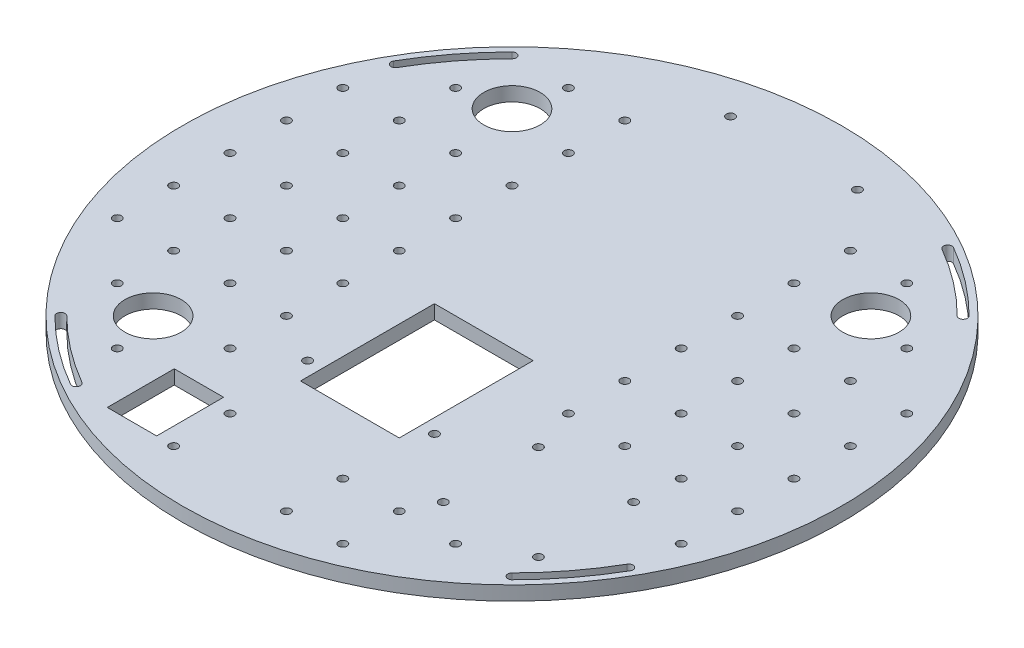
from build123d import *

# Parameters (mm, degrees)
SKETCH18_R            = 148.43125
BOSS_EXTRUDE1_DEPTH   = 6.35
F_6_CLEARANCE_HOLE1_D = 3.7973
CUT_EXTRUDE1_DEPTH    = 6.35
F_6_CLEARANCE_HOLE2_D = 3.7973
SKETCH29_W            = 44.45
SKETCH29_H            = 60.325
CUT_EXTRUDE2_DEPTH    = 7.35
SKETCH30_R            = 12.7
SKETCH30_W            = 22.225
SKETCH30_H            = 30.1625
CUT_EXTRUDE3_DEPTH    = 6.35
F_6_CLEARANCE_HOLE3_D = 3.7973


with BuildPart() as part:
    # Sketch18 → Boss-Extrude1 (new body)
    with BuildSketch(Plane(origin=(0, 0, 0), x_dir=(1, 0, 0), z_dir=(0, 1, 0))):
        Circle(SKETCH18_R)
    extrude(amount=BOSS_EXTRUDE1_DEPTH)

    # #6 Clearance Hole1 (through all)
    with Locations(Plane(origin=(0, 6.35, 0), x_dir=(1, 0, 0), z_dir=(0, 1, 0))):
        with Locations((-101.6, 101.6), (101.6, 101.6), (101.6, -101.6), (-101.6, -101.6), (-124.434078933, 71.842048969), (-71.842048969, -124.434078933), (124.434078933, -71.842048969), (71.842048969, 124.434078933)):
            Hole(F_6_CLEARANCE_HOLE1_D / 2)

    # Sketch23 → Cut-Extrude1 (cut)
    with BuildSketch(Plane(origin=(0, 6.35, 0), x_dir=(1, 0, 0), z_dir=(0, 1, 0))):
        with BuildLine():
            ThreePointArc((-72.791373969, -126.078358066), (-73.486328101, -123.484753933), (-70.892723969, -122.7897998))
            ThreePointArc((-70.892723969, -122.7897998), (-86.313511899, -112.485958726), (-100.25745171, -100.25745171))
            ThreePointArc((-100.25745171, -100.25745171), (-99.845876126, -100.873418101), (-99.70135, -101.6))
            ThreePointArc((-99.70135, -101.6), (-100.873418101, -103.354123874), (-102.94254829, -102.94254829))
            ThreePointArc((-102.94254829, -102.94254829), (-88.625161673, -115.498559365), (-72.791373969, -126.078358066))
        make_face()
        with BuildLine():
            ThreePointArc((-100.25745171, 100.25745171), (-102.94254829, 100.25745171), (-102.94254829, 102.94254829))
            ThreePointArc((-102.94254829, 102.94254829), (-115.498559365, 88.625161673), (-126.078358066, 72.791373969))
            ThreePointArc((-126.078358066, 72.791373969), (-123.942672153, 73.676004039), (-122.535428933, 71.842048969))
            ThreePointArc((-122.535428933, 71.842048969), (-122.600123863, 71.350642189), (-122.7897998, 70.892723969))
            ThreePointArc((-122.7897998, 70.892723969), (-112.485958726, 86.313511899), (-100.25745171, 100.25745171))
        make_face()
        with BuildLine():
            ThreePointArc((100.25745171, 100.25745171), (100.25745171, 102.94254829), (102.94254829, 102.94254829))
            ThreePointArc((102.94254829, 102.94254829), (88.625161673, 115.498559365), (72.791373969, 126.078358066))
            ThreePointArc((72.791373969, 126.078358066), (73.486328101, 125.383403933), (73.740698969, 124.434078933))
            ThreePointArc((73.740698969, 124.434078933), (72.791373969, 122.7897998), (70.892723969, 122.7897998))
            ThreePointArc((70.892723969, 122.7897998), (86.313511899, 112.485958726), (100.25745171, 100.25745171))
        make_face()
        with BuildLine():
            ThreePointArc((126.078358066, -72.791373969), (123.484753933, -73.486328101), (122.7897998, -70.892723969))
            ThreePointArc((122.7897998, -70.892723969), (112.485958726, -86.313511899), (100.25745171, -100.25745171))
            ThreePointArc((100.25745171, -100.25745171), (102.326581899, -99.845876126), (103.49865, -101.6))
            ThreePointArc((103.49865, -101.6), (103.354123874, -102.326581899), (102.94254829, -102.94254829))
            ThreePointArc((102.94254829, -102.94254829), (115.498559365, -88.625161673), (126.078358066, -72.791373969))
        make_face()
    extrude(amount=-CUT_EXTRUDE1_DEPTH, mode=Mode.SUBTRACT)

    # #6 Clearance Hole2 (through all)
    with Locations(Plane(origin=(0, 6.35, 0), x_dir=(1, 0, 0), z_dir=(0, 1, 0))):
        with Locations((57.15, -45.24375), (57.15, -88.10625), (100.0125, -88.10625), (100.0125, -45.24375), (-28.575, -63.5), (28.575, -63.5), (-28.575, 127), (28.575, 127)):
            Hole(F_6_CLEARANCE_HOLE2_D / 2)

    # Sketch29 → Cut-Extrude2 (cut, through all)
    with BuildSketch(Plane(origin=(0, 6.35, 0), x_dir=(1, 0, 0), z_dir=(0, 1, 0))):
        with Locations((0, -42.8625)):
            Rectangle(SKETCH29_W, SKETCH29_H)
    extrude(amount=-CUT_EXTRUDE2_DEPTH, mode=Mode.SUBTRACT)

    # Sketch30 → Cut-Extrude3 (cut)
    with BuildSketch(Plane(origin=(0, 6.35, 0), x_dir=(1, 0, 0), z_dir=(0, 1, 0))):
        with Locations((-80.82230509, 80.82230509)):
            Circle(SKETCH30_R)
        with Locations((80.82230509, 80.82230509)):
            Circle(SKETCH30_R)
        with Locations((-80.82230509, -80.82230509)):
            Circle(SKETCH30_R)
        with Locations((-44.30980509, -111.77855509)):
            Rectangle(SKETCH30_W, SKETCH30_H)
    extrude(amount=-CUT_EXTRUDE3_DEPTH, mode=Mode.SUBTRACT)

    # #6 Clearance Hole3 (through all)
    with Locations(Plane(origin=(0, 6.35, 0), x_dir=(1, 0, 0), z_dir=(0, 1, 0))):
        with Locations((-50.8, 101.6), (-76.2, 101.6), (-101.6, 76.2), (-50.8, 76.2), (-50.8, 50.8), (-76.2, 50.8), (-101.6, 50.8), (-127, 50.8), (-50.8, 25.4), (-76.2, 25.4), (-101.6, 25.4), (-127, 25.4), (-101.6, 0), (-127, 0), (-127, -25.4), (-101.6, -25.4), (-127, -50.8), (-101.6, -50.8), (-101.6, -76.2), (-76.2, -101.6), (-50.8, -76.2), (-76.2, -50.8), (-50.8, -50.8), (-50.8, -25.4), (-76.2, -25.4), (-76.2, 0), (-50.8, 0), (50.8, 101.6), (76.2, 101.6), (50.8, 76.2), (101.6, 76.2), (101.6, 50.8), (127, 50.8), (127, 25.4), (127, 0), (127, -25.4), (50.8, 50.8), (50.8, 25.4), (50.8, 0), (50.8, -25.4), (76.2, -25.4), (101.6, -25.4), (101.6, 0), (76.2, 0), (76.2, 25.4), (76.2, 50.8), (101.6, 25.4), (127, -50.8), (76.2, -101.6), (50.8, -101.6), (-25.4, -101.6), (25.4, -101.6), (25.4, -127), (50.8, -127), (-25.4, -127)):
            Hole(F_6_CLEARANCE_HOLE3_D / 2)


solid = part.part
